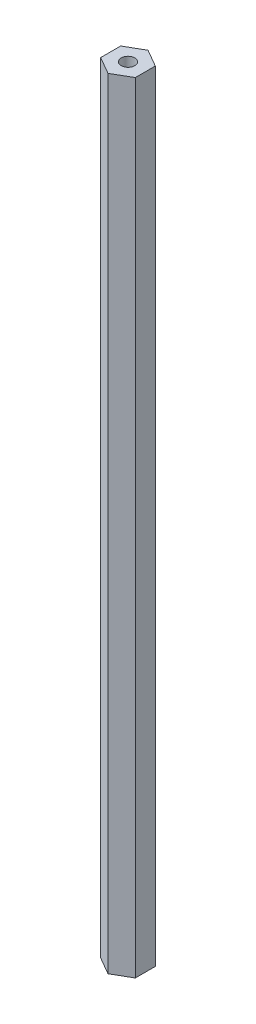
from build123d import *

# Parameters (mm, degrees)
BOSS_EXTRUDE1_DEPTH = 285.75
SKETCH2_R           = 2.4892
CUT_EXTRUDE1_DEPTH  = 25.4
SKETCH3_R           = 2.4892
CUT_EXTRUDE2_DEPTH  = 25.4


with BuildPart() as part:
    # Sketch1 → Boss-Extrude1 (new body)
    with BuildSketch(Plane(origin=(0, 0, 0), x_dir=(1, 0, 0), z_dir=(0, 1, 0))):
        Polygon((6.35, 3.666174209), (0, 7.332348419), (-6.35, 3.666174209), (-6.35, -3.666174209), (0, -7.332348419), (6.35, -3.666174209), align=None)
    extrude(amount=BOSS_EXTRUDE1_DEPTH)

    # Sketch2 → Cut-Extrude1 (cut)
    with BuildSketch(Plane.XZ):
        Circle(SKETCH2_R)
    extrude(amount=-CUT_EXTRUDE1_DEPTH, mode=Mode.SUBTRACT)

    # Sketch3 → Cut-Extrude2 (cut)
    with BuildSketch(Plane(origin=(0, 285.75, 0), x_dir=(1, 0, 0), z_dir=(0, 1, 0))):
        Circle(SKETCH3_R)
    extrude(amount=-CUT_EXTRUDE2_DEPTH, mode=Mode.SUBTRACT)


solid = part.part
